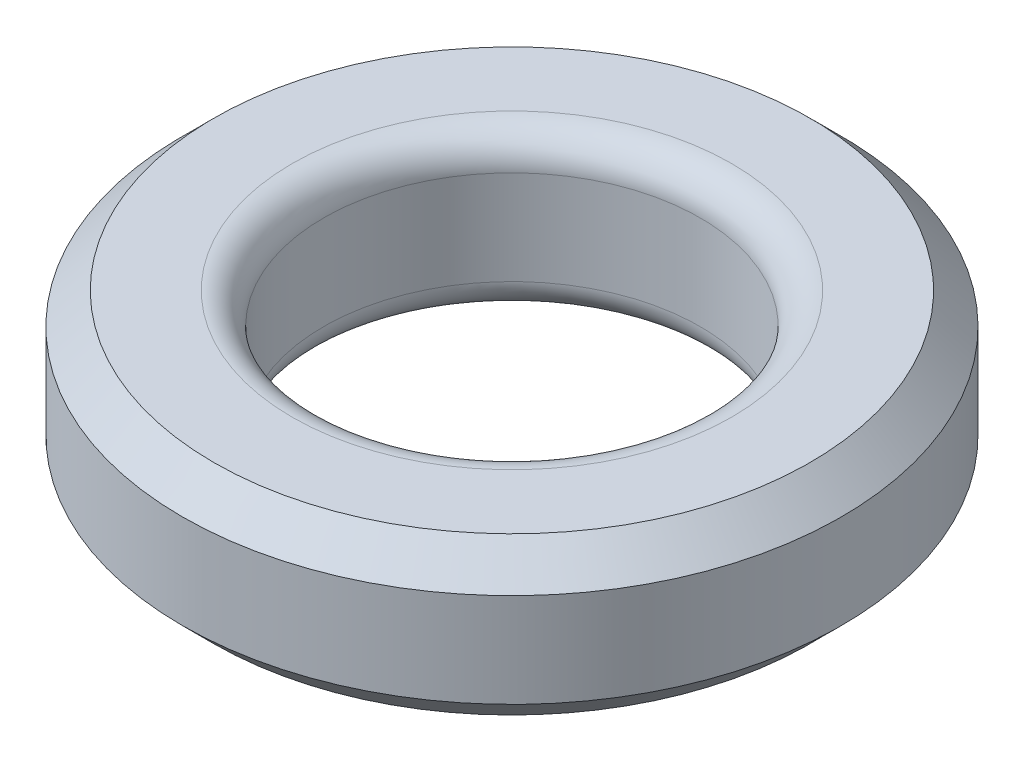
from build123d import *

# Parameters (mm, degrees)
SKETCH_1_R      = 10.5
SKETCH_1_R_2    = 6
EXTRUDE_1_DEPTH = 5
FILLET_1_R      = 1
CHAMFER_1_SIZE  = 1


with BuildPart() as part:
    # Эскиз1 → Бобышка-Вытянуть1 (new body)
    with BuildSketch(Plane(origin=(0, 0, 0), x_dir=(1, 0, 0), z_dir=(0, 1, 0))):
        Circle(SKETCH_1_R)
        Circle(SKETCH_1_R_2, mode=Mode.SUBTRACT)
    extrude(amount=EXTRUDE_1_DEPTH)

    # Скругление1
    fillet_1_edges = [part.edges().sort_by_distance(p)[0] for p in [
        (-6, 0, 0),
        (-6, 5, 0),
    ]]
    fillet(fillet_1_edges, radius=FILLET_1_R)

    # Фаска1
    chamfer_1_edges = [part.edges().sort_by_distance(p)[0] for p in [
        (-10.5, 0, 0),
        (-10.5, 5, 0),
    ]]
    chamfer(chamfer_1_edges, length=CHAMFER_1_SIZE)


solid = part.part
